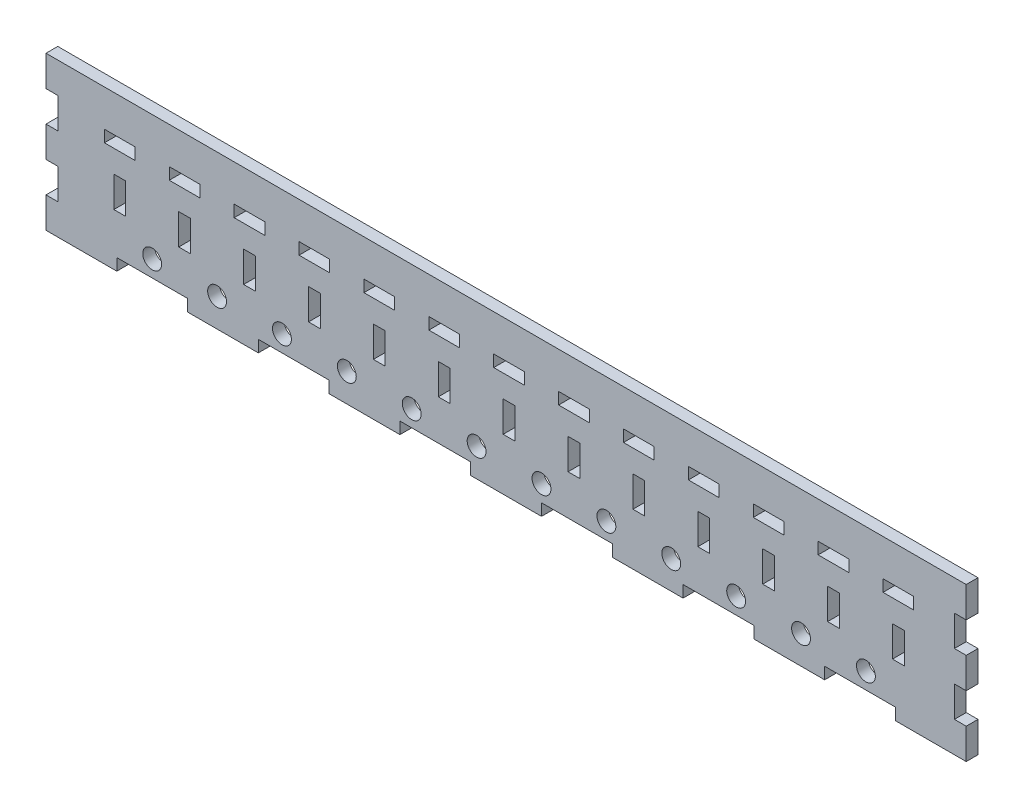
from build123d import *

# Parameters (mm, degrees)
ESQUISSE1_W                    = 390
ESQUISSE1_H                    = 65
BOSS_EXTRU_1_DEPTH             = 5
ESQUISSE2_W                    = 30
ESQUISSE2_H                    = 5
ENL_V_MAT_EXTRU_1_DEPTH        = 5
R_P_TITION_LIN_AIRE1_COUNT     = 6
R_P_TITION_LIN_AIRE1_PITCH     = 60
ESQUISSE3_W                    = 5
ESQUISSE3_H                    = 13
ENL_V_MAT_EXTRU_2_DEPTH        = 5
R_P_TITION_LIN_AIRE2_COUNT     = 2
R_P_TITION_LIN_AIRE2_PITCH     = 26
SYM_TRIE1_COPY_1_SKETCH_W      = 5
SYM_TRIE1_COPY_1_SKETCH_H      = 13
SYM_TRIE1_COPY_1_DEPTH         = 5
ESQUISSE4_R                    = 4
ENL_V_MAT_EXTRU_3_DEPTH        = 5
R_P_TITION_LIN_AIRE3_COUNT     = 10
R_P_TITION_LIN_AIRE3_PITCH     = 27.5
R_P_TITION_LIN_AIRE3_COL_COUNT = 3
R_P_TITION_LIN_AIRE3_COL_PITCH = 27.5
ESQUISSE5_W                    = 5
ESQUISSE5_H                    = 13
ESQUISSE5_W_2                  = 13
ESQUISSE5_H_2                  = 5
ENL_V_MAT_EXTRU_4_DEPTH        = 5
R_P_TITION_LIN_AIRE4_COUNT     = 3
R_P_TITION_LIN_AIRE4_PITCH     = 27.5
R_P_TITION_LIN_AIRE4_COL_COUNT = 11
R_P_TITION_LIN_AIRE4_COL_PITCH = 27.5


with BuildPart() as part:
    # Esquisse1 → Boss.-Extru.1 (new body)
    with BuildSketch(Plane.XY):
        with Locations((195, -32.5)):
            Rectangle(ESQUISSE1_W, ESQUISSE1_H)
    extrude(amount=BOSS_EXTRU_1_DEPTH)

    # Esquisse2 → Enlèv. mat.-Extru.1 (cut)
    with BuildSketch(Plane.XY.offset(5)):
        with Locations((45, -62.5)):
            Rectangle(ESQUISSE2_W, ESQUISSE2_H)
    enl_v_mat_extru_1 = extrude(amount=-ENL_V_MAT_EXTRU_1_DEPTH, mode=Mode.SUBTRACT)

    # Répétition linéaire1: Enlèv. mat.-Extru.1 ×6
    with Locations(*[(i * R_P_TITION_LIN_AIRE1_PITCH, 0, 0) for i in range(1, R_P_TITION_LIN_AIRE1_COUNT)]):
        add(enl_v_mat_extru_1, mode=Mode.SUBTRACT)

    # Esquisse3 → Enlèv. mat.-Extru.2 (cut)
    with BuildSketch(Plane.XY.offset(5)):
        with Locations((2.5, -45.5)):
            Rectangle(ESQUISSE3_W, ESQUISSE3_H)
    enl_v_mat_extru_2 = extrude(amount=-ENL_V_MAT_EXTRU_2_DEPTH, mode=Mode.SUBTRACT)

    # Répétition linéaire2: Enlèv. mat.-Extru.2 ×2
    with Locations(*[(0, i * R_P_TITION_LIN_AIRE2_PITCH, 0) for i in range(1, R_P_TITION_LIN_AIRE2_COUNT)]):
        add(enl_v_mat_extru_2, mode=Mode.SUBTRACT)

    # Symétrie1: Enlèv. mat.-Extru.2 across plane
    add(enl_v_mat_extru_2.mirror(Plane.ZY.offset(-195)), mode=Mode.SUBTRACT)

    # Symétrie1 copy 1 sketch → Symétrie1 copy 1 (cut)
    with BuildSketch(Plane(origin=(390, 26, 5), x_dir=(-1, 0, 0), z_dir=(0, 0, 1))):
        with Locations((2.5, 45.5)):
            Rectangle(SYM_TRIE1_COPY_1_SKETCH_W, SYM_TRIE1_COPY_1_SKETCH_H)
    extrude(amount=-SYM_TRIE1_COPY_1_DEPTH, mode=Mode.SUBTRACT)

    # Esquisse4 → Enlèv. mat.-Extru.3 (cut)
    with BuildSketch(Plane.XY.offset(5)):
        with Locations((100, -53)):
            Circle(ESQUISSE4_R)
    enl_v_mat_extru_3 = extrude(amount=-ENL_V_MAT_EXTRU_3_DEPTH, mode=Mode.SUBTRACT)

    # Répétition linéaire3: Enlèv. mat.-Extru.3 ×10
    with Locations(*[(i * R_P_TITION_LIN_AIRE3_PITCH, 0, 0) for i in range(1, R_P_TITION_LIN_AIRE3_COUNT)]):
        add(enl_v_mat_extru_3, mode=Mode.SUBTRACT)

    # Répétition linéaire3 col: Enlèv. mat.-Extru.3 ×3
    with Locations(*[(-i * R_P_TITION_LIN_AIRE3_COL_PITCH, 0, 0) for i in range(1, R_P_TITION_LIN_AIRE3_COL_COUNT)]):
        add(enl_v_mat_extru_3, mode=Mode.SUBTRACT)

    # Esquisse5 → Enlèv. mat.-Extru.4 (cut)
    with BuildSketch(Plane.XY.offset(5)):
        with Locations((86.25, -36.5)):
            Rectangle(ESQUISSE5_W, ESQUISSE5_H)
        with Locations((86.25, -18)):
            Rectangle(ESQUISSE5_W_2, ESQUISSE5_H_2)
    enl_v_mat_extru_4 = extrude(amount=-ENL_V_MAT_EXTRU_4_DEPTH, mode=Mode.SUBTRACT)

    # Répétition linéaire4: Enlèv. mat.-Extru.4 ×3
    with Locations(*[(-i * R_P_TITION_LIN_AIRE4_PITCH, 0, 0) for i in range(1, R_P_TITION_LIN_AIRE4_COUNT)]):
        add(enl_v_mat_extru_4, mode=Mode.SUBTRACT)

    # Répétition linéaire4 col: Enlèv. mat.-Extru.4 ×11
    with Locations(*[(i * R_P_TITION_LIN_AIRE4_COL_PITCH, 0, 0) for i in range(1, R_P_TITION_LIN_AIRE4_COL_COUNT)]):
        add(enl_v_mat_extru_4, mode=Mode.SUBTRACT)


solid = part.part
